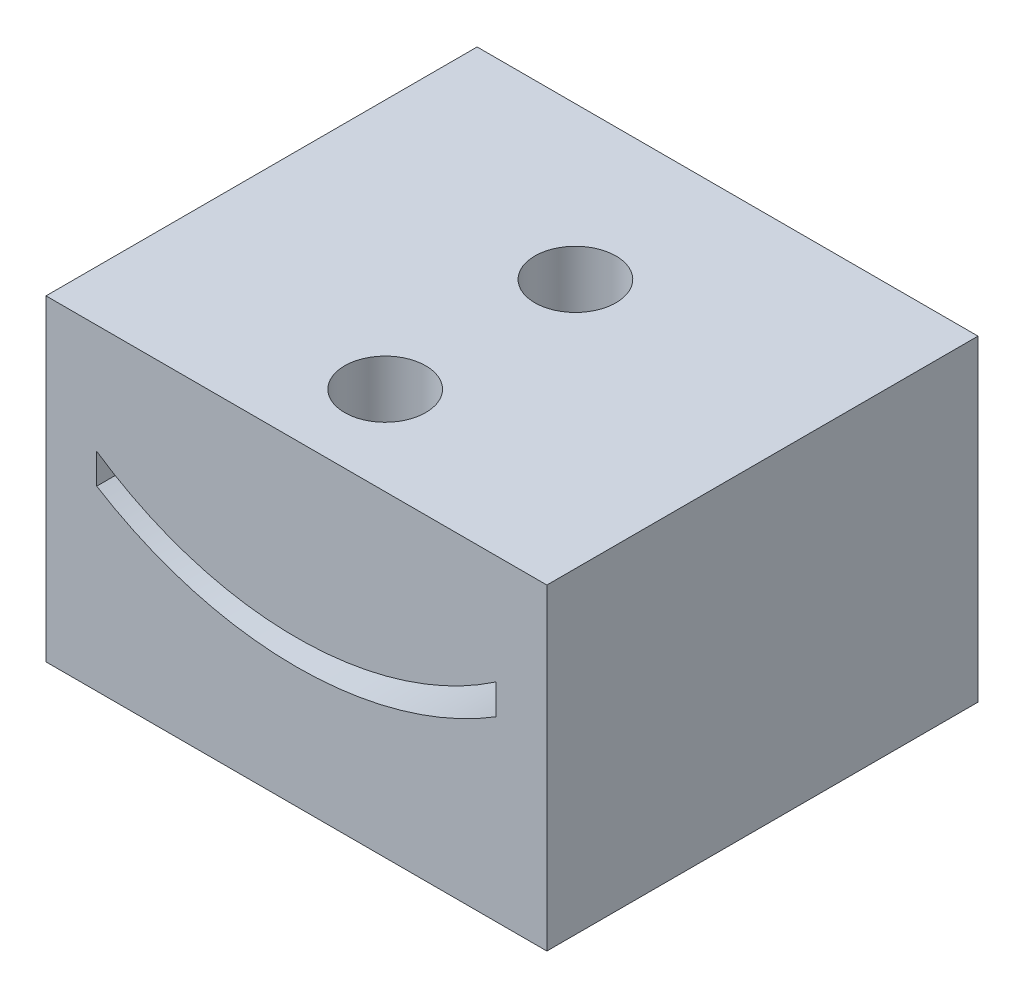
from build123d import *

# Parameters (mm, degrees)
SKETCH1_W           = 19.75
SKETCH1_H           = 12.5
BOSS_EXTRUDE1_DEPTH = 15
SKETCH2_R           = 1.6
CUT_EXTRUDE1_DEPTH  = 13.5
SKETCH3_W           = 19.75
SKETCH3_H           = 12.5
BOSS_EXTRUDE2_DEPTH = 2


with BuildPart() as part:
    # Sketch1 → Boss-Extrude1 (new body)
    with BuildSketch(Plane.XY):
        with Locations((9.875, 6.25)):
            Rectangle(SKETCH1_W, SKETCH1_H)
        with BuildLine():
            Line((17.75, 8.191371412), (17.75, 7))
            ThreePointArc((17.75, 7), (9.875, 4.766533398), (2, 7))
            Line((2, 7), (2, 8.191371412))
            ThreePointArc((2, 8.191371412), (9.875, 5.766533398), (17.75, 8.191371412))
        make_face(mode=Mode.SUBTRACT)
    extrude(amount=BOSS_EXTRUDE1_DEPTH)

    # Sketch2 → Cut-Extrude1 (cut, through all)
    with BuildSketch(Plane(origin=(0, 12.5, 0), x_dir=(1, 0, 0), z_dir=(0, 1, 0))):
        with Locations((9.875, -11.5)):
            Circle(SKETCH2_R)
        with Locations((9.875, -4)):
            Circle(SKETCH2_R)
    extrude(amount=-CUT_EXTRUDE1_DEPTH, mode=Mode.SUBTRACT)

    # Sketch3 → Boss-Extrude2 (add)
    with BuildSketch(Plane(origin=(0, 0, 0), x_dir=(-1, 0, 0), z_dir=(0, 0, -1))):
        with Locations((-9.875, 6.25)):
            Rectangle(SKETCH3_W, SKETCH3_H)
    extrude(amount=BOSS_EXTRUDE2_DEPTH)


solid = part.part
